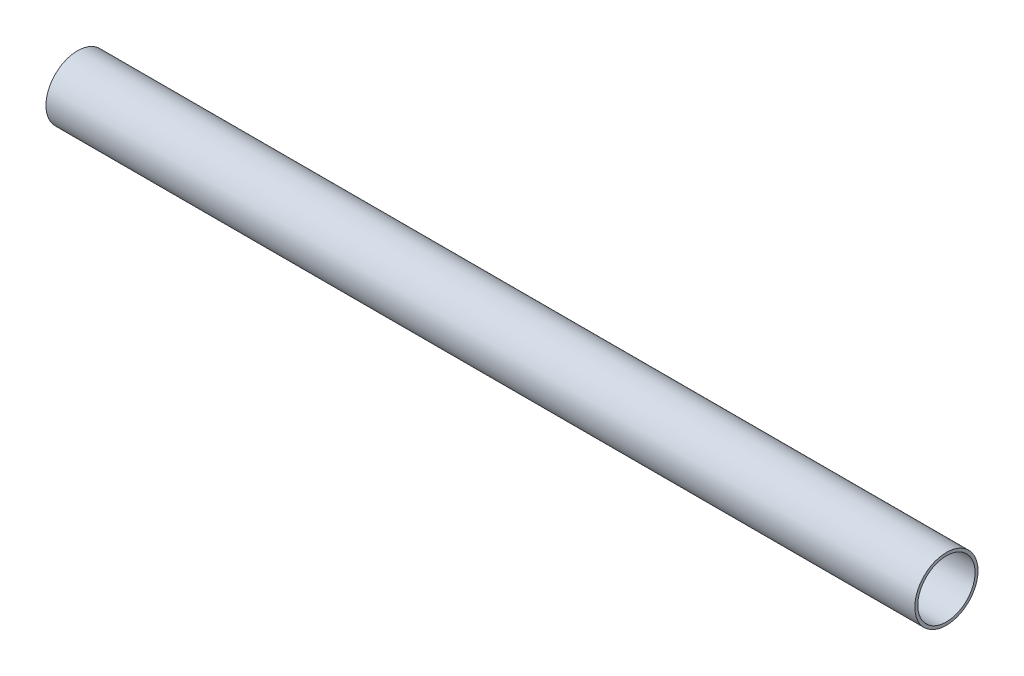
from build123d import *

# Parameters (mm, degrees)
SKETCH1_W = 220
SKETCH1_H = 0.75


with BuildPart() as part:
    # Sketch1 → Revolve1 (revolve)
    with BuildSketch(Plane.XY):
        with Locations((110, 7.625)):
            Rectangle(SKETCH1_W, SKETCH1_H)
    revolve(axis=Axis((0, 0, 0), (1, 0, 0)))


solid = part.part
